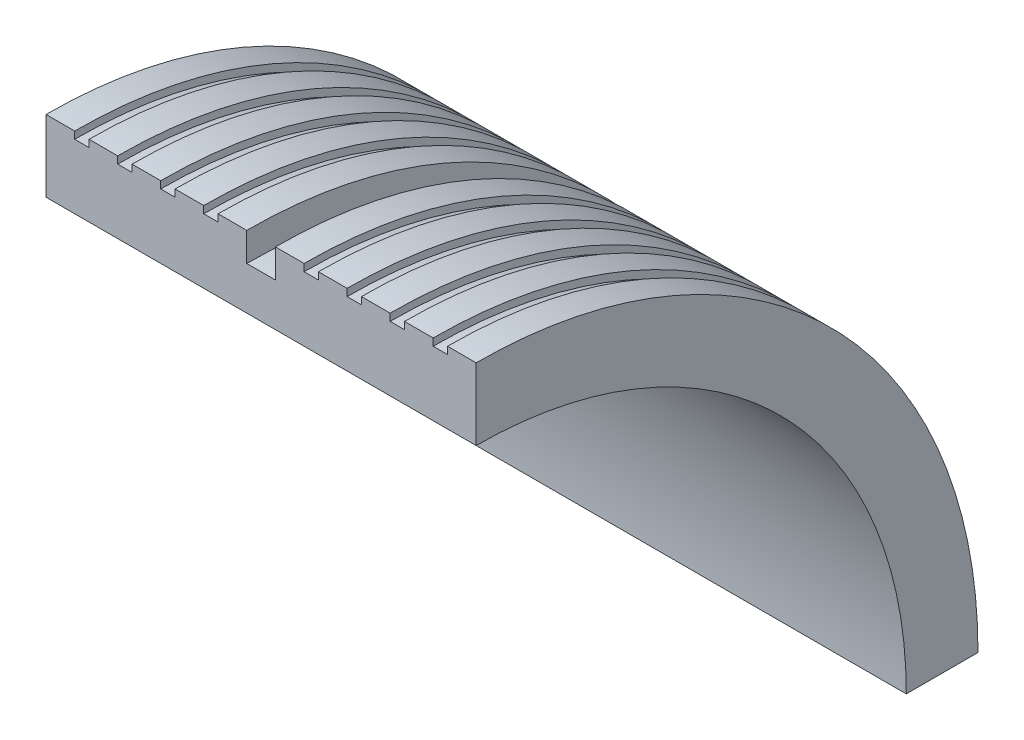
from build123d import *

# Parameters (mm, degrees)
BOSS_EXTRUDE1_DEPTH = 30
SKETCH2_W           = 1
SKETCH2_H           = 1
SKETCH2_W_2         = 2
SKETCH2_H_2         = 2


with BuildPart() as part:
    # Sketch1 → Boss-Extrude1 (new body)
    with BuildSketch(Plane(origin=(0, 0, 0), x_dir=(0, 0, -1), z_dir=(1, 0, 0))):
        with BuildLine():
            Line((0, 35), (0, 30))
            ThreePointArc((0, 30), (21.213203436, 21.213203436), (30, 0))
            Line((30, 0), (35, 0))
            ThreePointArc((35, 0), (24.748737342, 24.748737342), (0, 35))
        make_face()
    extrude(amount=BOSS_EXTRUDE1_DEPTH)

    # Sketch2 → Cut-Revolve1 (revolve, cut)
    with BuildSketch(Plane.XY):
        with Locations((2.5, 35)):
            Rectangle(SKETCH2_W, SKETCH2_H)
        with Locations((5.5, 35)):
            Rectangle(SKETCH2_W, SKETCH2_H)
        with Locations((8.5, 35)):
            Rectangle(SKETCH2_W, SKETCH2_H)
        with Locations((11.5, 35)):
            Rectangle(SKETCH2_W, SKETCH2_H)
        with Locations((18.5, 35)):
            Rectangle(SKETCH2_W, SKETCH2_H)
        with Locations((21.5, 35)):
            Rectangle(SKETCH2_W, SKETCH2_H)
        with Locations((24.5, 35)):
            Rectangle(SKETCH2_W, SKETCH2_H)
        with Locations((27.5, 35)):
            Rectangle(SKETCH2_W, SKETCH2_H)
        with Locations((15, 34)):
            Rectangle(SKETCH2_W_2, SKETCH2_H_2)
    revolve(axis=Axis((30, 0, 0), (-1, 0, 0)), mode=Mode.SUBTRACT)


solid = part.part
